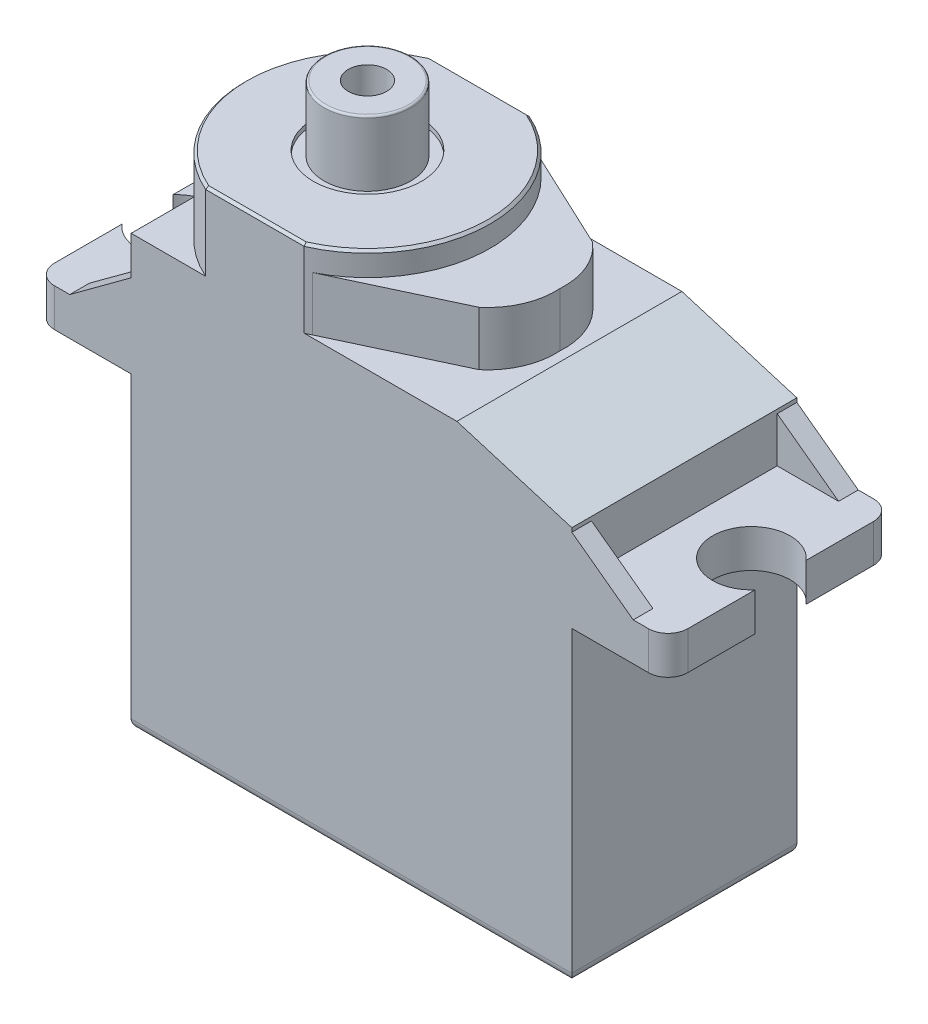
from build123d import *

# Parameters (mm, degrees)
SKETCH1_W            = 22.7838
SKETCH1_H            = 11.6332
BOSS_EXTRUDE1_DEPTH  = 15.9512
FILLET1_R            = 0.508
BOSS_EXTRUDE3_DEPTH  = 11.6332
CUT_EXTRUDE1_DEPTH   = 4.0132
CHAMFER1_SIZE        = 0.127
FILLET2_R            = 1.016
SKETCH7_R            = 2.0066
CUT_EXTRUDE2_DEPTH   = 18.9197
BOSS_EXTRUDE4_DEPTH  = 2.794
SKETCH9_R            = 2.794
CUT_EXTRUDE3_DEPTH   = 0.254
BOSS_EXTRUDE5_DEPTH  = 1.016
BOSS_EXTRUDE6_DEPTH  = 1.016
SKETCH12_R           = 2.2479
SKETCH12_R_2         = 0.9906
BOSS_EXTRUDE10_DEPTH = 3.3782
FILLET3_R            = 0.1016


with BuildPart() as part:
    # Sketch1 → Boss-Extrude1 (new body)
    with BuildSketch(Plane(origin=(0, 0, 0), x_dir=(1, 0, 0), z_dir=(0, 1, 0))):
        with Locations((-11.3919, -5.8166)):
            Rectangle(SKETCH1_W, SKETCH1_H)
    extrude(amount=BOSS_EXTRUDE1_DEPTH)

    # Fillet1
    fillet1_edges = [part.edges().sort_by_distance(p)[0] for p in [
        (-11.3919, 0, 11.6332),
        (-22.7838, 0, 5.8166),
        (-11.3919, 0, 0),
        (0, 0, 5.8166),
    ]]
    fillet(fillet1_edges, radius=FILLET1_R)

    # Sketch5 → Boss-Extrude3 (add)
    with BuildSketch(Plane.XY.offset(11.6332)):
        Polygon((0, 15.9512), (4.9784, 15.9512), (4.9784, 17.9197), (0, 17.9197), (0, 20.4597), (-5.9436, 22.2504), (-7.512738225, 22.2504), (-7.512738225, 26.2636), (-22.7838, 26.2636), (-22.7838, 17.9197), (-27.7622, 17.9197), (-27.7622, 15.9512), (-22.7838, 15.9512), align=None)
    extrude(amount=-BOSS_EXTRUDE3_DEPTH)

    # Sketch6 → Cut-Extrude1 (cut)
    with BuildSketch(Plane(origin=(0, 26.2636, 0), x_dir=(1, 0, 0), z_dir=(0, 1, 0))):
        with BuildLine():
            Line((-18.93048198, 0), (-22.7838, 0))
            Line((-22.7838, 0), (-22.7838, -11.6332))
            Line((-22.7838, -11.6332), (-18.93048198, -11.6332))
            ThreePointArc((-18.93048198, -11.6332), (-22.733, -5.8166), (-18.93048198, 0))
        make_face()
        with BuildLine():
            Line((-7.512738225, 0), (-13.83551802, 0))
            ThreePointArc((-13.83551802, 0), (-11.067973632, -2.341978479), (-10.033, -5.8166))
            ThreePointArc((-10.033, -5.8166), (-11.067973632, -9.291221521), (-13.83551802, -11.6332))
            Line((-13.83551802, -11.6332), (-7.512738225, -11.6332))
            Line((-7.512738225, -11.6332), (-7.512738225, 0))
        make_face()
    extrude(amount=-CUT_EXTRUDE1_DEPTH, mode=Mode.SUBTRACT)

    # Chamfer1
    chamfer1_edges = [part.edges().sort_by_distance(p)[0] for p in [
        (-16.383, 26.2636, 11.6332),
        (-22.733, 26.2636, 5.8166),
        (-16.383, 26.2636, 0),
        (-10.033, 26.2636, 5.8166),
    ]]
    chamfer(chamfer1_edges, length=CHAMFER1_SIZE)

    # Fillet2
    fillet2_edges = [part.edges().sort_by_distance(p)[0] for p in [
        (-27.7622, 16.93545, 0),
        (-27.7622, 16.93545, 11.6332),
        (4.9784, 16.93545, 0),
        (4.9784, 16.93545, 11.6332),
    ]]
    fillet(fillet2_edges, radius=FILLET2_R)

    # Sketch7 → Cut-Extrude2 (cut, through all)
    with BuildSketch(Plane(origin=(0, 17.9197, 0), x_dir=(1, 0, 0), z_dir=(0, 1, 0))):
        with Locations((3.4671, -5.8166)):
            Circle(SKETCH7_R)
        with Locations((-26.2509, -5.8166)):
            Circle(SKETCH7_R)
    extrude(amount=-CUT_EXTRUDE2_DEPTH, mode=Mode.SUBTRACT)

    # Sketch8 → Boss-Extrude4 (add)
    with BuildSketch(Plane(origin=(0, 22.2504, 0), x_dir=(1, 0, 0), z_dir=(0, 1, 0))):
        with BuildLine():
            Line((-7.679090009, -2.88804007), (-13.538580336, -0.139296346))
            ThreePointArc((-13.538580336, -0.139296346), (-10.033, -5.8166), (-13.538580336, -11.493903654))
            Line((-13.538580336, -11.493903654), (-7.679090009, -8.74515993))
            ThreePointArc((-7.679090009, -8.74515993), (-6.704959334, -7.430304447), (-6.433420255, -5.8166))
            ThreePointArc((-6.433420255, -5.8166), (-6.704959334, -4.202895553), (-7.679090009, -2.88804007))
        make_face()
    extrude(amount=BOSS_EXTRUDE4_DEPTH)

    # Sketch9 → Cut-Extrude3 (cut)
    with BuildSketch(Plane(origin=(0, 26.2636, 0), x_dir=(1, 0, 0), z_dir=(0, 1, 0))):
        with Locations((-16.383, -5.8166)):
            Circle(SKETCH9_R)
    extrude(amount=-CUT_EXTRUDE3_DEPTH, mode=Mode.SUBTRACT)

    # Sketch10 → Boss-Extrude5 (add)
    with BuildSketch(Plane.XY.offset(11.6332)):
        Polygon((0, 20.2565), (3.175, 17.9197), (0, 17.9197), align=None)
        Polygon((-22.7838, 17.9197), (-22.7838, 20.2565), (-25.9588, 17.9197), align=None)
    extrude(amount=-BOSS_EXTRUDE5_DEPTH)

    # Sketch11 → Boss-Extrude6 (add)
    with BuildSketch(Plane(origin=(0, 0, 0), x_dir=(-1, 0, 0), z_dir=(0, 0, -1))):
        Polygon((22.7838, 20.2565), (22.7838, 17.9197), (25.9588, 17.9197), align=None)
        Polygon((0, 20.2565), (-3.175, 17.9197), (0, 17.9197), align=None)
    extrude(amount=-BOSS_EXTRUDE6_DEPTH)

    # Sketch12 → Boss-Extrude10 (add)
    with BuildSketch(Plane(origin=(0, 26.0096, 0), x_dir=(1, 0, 0), z_dir=(0, 1, 0))):
        with Locations((-16.383, -5.8166)):
            Circle(SKETCH12_R)
        with Locations((-16.383, -5.8166)):
            Circle(SKETCH12_R_2, mode=Mode.SUBTRACT)
    extrude(amount=BOSS_EXTRUDE10_DEPTH)

    # Fillet3
    fillet3_edges = [part.edges().sort_by_distance(p)[0] for p in [
        (-18.6309, 29.3878, 5.8166),
    ]]
    fillet(fillet3_edges, radius=FILLET3_R)


solid = part.part
